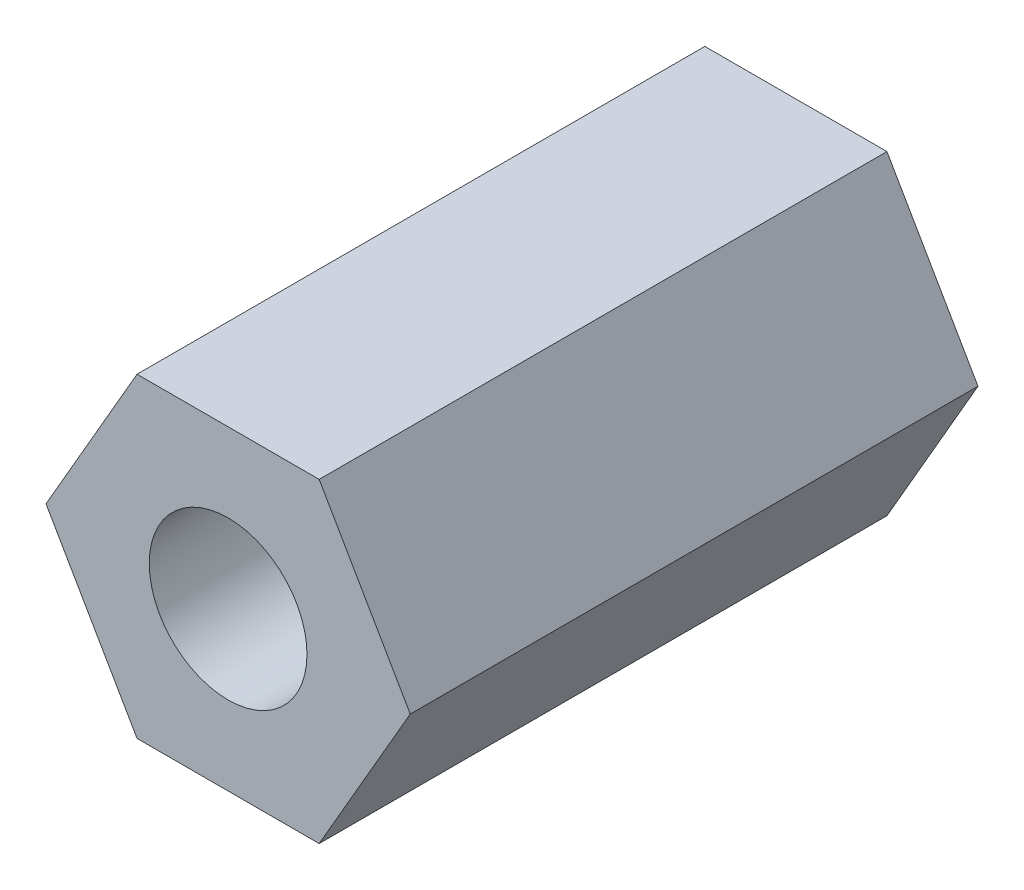
from build123d import *

# Parameters (mm, degrees)
EXTRUDE_1_DEPTH = 9
M3X0_5_1_D      = 2.5


with BuildPart() as part:
    # 草圖1 → 填料-伸長1 (new body)
    with BuildSketch(Plane.XY):
        Polygon((-1.443375673, 2.5), (-2.886751346, 0), (-1.443375673, -2.5), (1.443375673, -2.5), (2.886751346, 0), (1.443375673, 2.5), align=None)
    extrude(amount=EXTRUDE_1_DEPTH)

    # M3x0.5 螺紋孔1 (through all)
    with Locations(Plane.XY.offset(9)):
        with Locations((0, 0)):
            Hole(M3X0_5_1_D / 2)


solid = part.part
